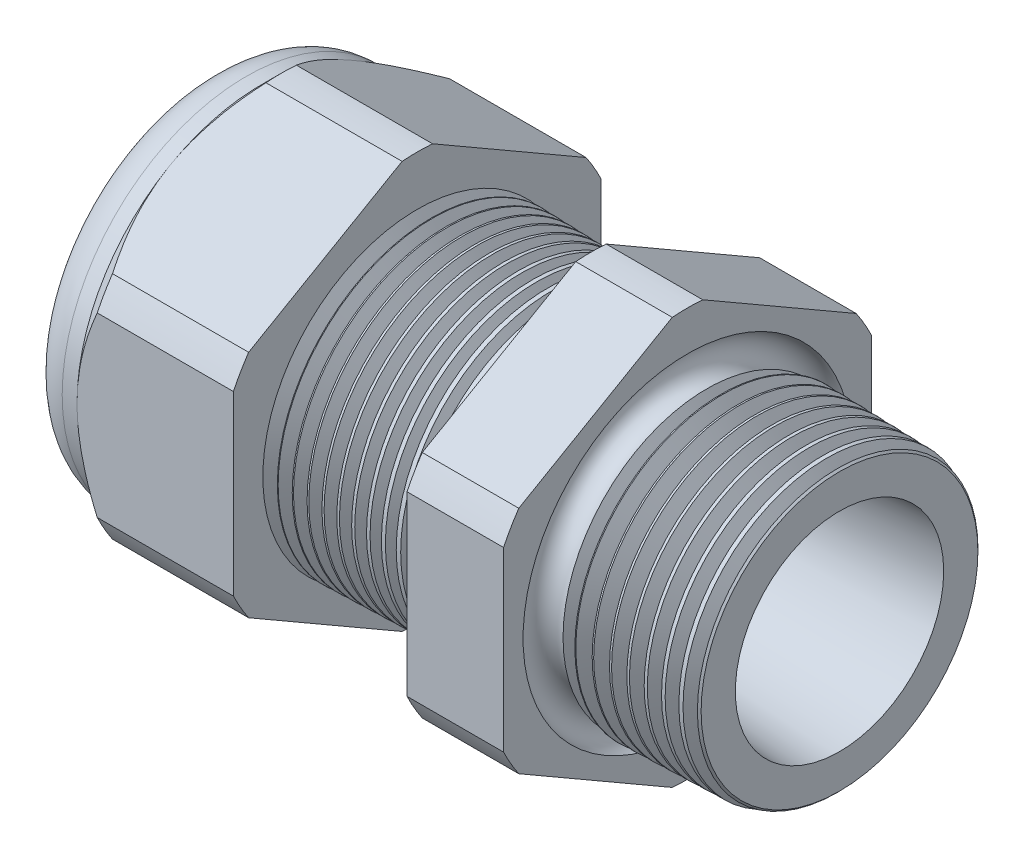
from build123d import *

# Parameters (mm, degrees)
SKETCH12_OUTSIDE_W = 52.712
SKETCH12_OUTSIDE_H = 52.712
CUT_EXTRUDE2_DEPTH = 30.966
FILLET4_R          = 2.032
SKETCH19_OUTSIDE_W = 33.73
SKETCH19_OUTSIDE_H = 35.826
SKETCH19_OUTSIDE_R = 9.525
CUT_EXTRUDE3_DEPTH = 1.999996
CUT_EXTRUDE3_DRAFT = -45
CHAMFER1_SIZE      = 0.260919487
CHAMFER1_SIZE2     = 0.254
SKETCH21_R         = 3.937
PLUG_DEPTH         = 3.81
SKETCH22_R         = 3.683
CUT_EXTRUDE4_DEPTH = 0.508
SKETCH27_R         = 1.778
PLUGHOLES_DEPTH    = 33.258
CIRPATTERN1_COUNT  = 2
LPATTERN1_COUNT    = 12
LPATTERN1_PITCH    = 0.762
LPATTERN2_COUNT    = 9
LPATTERN2_PITCH    = 0.889
SKETCH32_R         = 0.889


with BuildPart() as part:
    # Sketch10 → Revolve2 (revolve)
    with BuildSketch(Plane.XY, mode=Mode.PRIVATE) as revolve2_sk:
        Polygon((-32.766, 3.937), (-21.866, 3.937), (0, 5.396418639), (0, 7.428418639), (-7.874, 7.634606585), (-7.874, 19.05), (-12.874, 19.05), (-12.874, 7.765536193), (-21.866, 8.001), (-21.866, 19.05), (-29.966, 19.05), (-29.966, 9.525), (-32.766, 9.525), align=None)
    revolve(revolve2_sk.sketch.rotate(Axis((0, 0, 0), (-1, 0, 0)), 90), axis=Axis((0, 0, 0), (-1, 0, 0)))  # turned: the seam where the file's is

    # Sketch12 outside → Cut-Extrude2 (cut, through all)
    with BuildSketch(Plane.ZY.offset(29.966)):
        Rectangle(SKETCH12_OUTSIDE_W, SKETCH12_OUTSIDE_H)
        with BuildLine():
            Line((-0.788451287, 10.543310065), (-8.736548713, 5.954473877))
            ThreePointArc((-8.736548713, 5.954473877), (-9.156270088, 5.286375), (-9.525, 4.588836188))
            Line((-9.525, 4.588836188), (-9.525, -4.588836188))
            ThreePointArc((-9.525, -4.588836188), (-9.156270088, -5.286375), (-8.736548713, -5.954473877))
            Line((-8.736548713, -5.954473877), (-0.788451287, -10.543310065))
            ThreePointArc((-0.788451287, -10.543310065), (0, -10.57275), (0.788451287, -10.543310065))
            Line((0.788451287, -10.543310065), (8.736548713, -5.954473877))
            ThreePointArc((8.736548713, -5.954473877), (9.156270088, -5.286375), (9.525, -4.588836188))
            Line((9.525, -4.588836188), (9.525, 4.588836188))
            ThreePointArc((9.525, 4.588836188), (9.156270088, 5.286375), (8.736548713, 5.954473877))
            Line((8.736548713, 5.954473877), (0.788451287, 10.543310065))
            ThreePointArc((0.788451287, 10.543310065), (0, 10.57275), (-0.788451287, 10.543310065))
        make_face(mode=Mode.SUBTRACT)
    extrude(amount=-CUT_EXTRUDE2_DEPTH, mode=Mode.SUBTRACT)

    # Fillet4
    fillet4_edges = [part.edges().sort_by_distance(p)[0] for p in [
        (-32.766, 0, 9.525),
    ]]
    fillet(fillet4_edges, radius=FILLET4_R)


with BuildPart() as cut_extrude3_tool:
    # Sketch19 outside → Cut-Extrude3 (with draft: the straight prism first)
    with BuildSketch(Plane.ZY.offset(29.966)):
        Rectangle(SKETCH19_OUTSIDE_W, SKETCH19_OUTSIDE_H)
        Circle(SKETCH19_OUTSIDE_R, mode=Mode.SUBTRACT)
    extrude(amount=-CUT_EXTRUDE3_DEPTH)
    # Cut-Extrude3: the draft: its side faces are tilted about the plane it starts from
    cut_extrude3_sides = [cut_extrude3_tool.faces().sort_by_distance(p)[0] for p in [
        (-28.966002, -17.913, 0),
        (-28.966002, 0, 16.865),
        (-28.966002, 17.913, 0),
        (-28.966002, 0, -16.865),
        (-28.966002, 0, -9.525),
    ]]
    draft(cut_extrude3_sides, Plane.ZY.offset(29.966), CUT_EXTRUDE3_DRAFT)


with BuildPart() as part_1:
    add(part.part)

    # Cut-Extrude3: cut by cut_extrude3_tool
    add(cut_extrude3_tool.part, mode=Mode.SUBTRACT)

    # Chamfer1
    chamfer1_edges = [part_1.edges().sort_by_distance(p)[0] for p in [
        (0, 0, 7.428418639),
    ]]
    chamfer1_side = [part_1.faces().sort_by_distance(p)[0] for p in [
        (0, 0, 5.606526047),
    ]]
    chamfer(chamfer1_edges, length=CHAMFER1_SIZE, length2=CHAMFER1_SIZE2, reference=chamfer1_side[0])

    # Sketch29 → Cut-Revolve1 (revolve, cut)
    with BuildSketch(Plane.XY, mode=Mode.PRIVATE) as cut_revolve1_sk:
        Polygon((-21.866, 8.001), (-21.133016419, 7.981806149), (-21.516130572, 7.356620673), align=None)
    cut_revolve1 = revolve(cut_revolve1_sk.sketch.rotate(Axis((0, 0, 0), (-1, 0, 0)), 90), axis=Axis((0, 0, 0), (-1, 0, 0)), mode=Mode.SUBTRACT)  # turned: the seam where the file's is

    # LPattern1: Cut-Revolve1 ×12
    with Locations(*[(i * LPATTERN1_PITCH, 0, 0) for i in range(1, LPATTERN1_COUNT)]):
        add(cut_revolve1, mode=Mode.SUBTRACT)

    # Sketch30 → Cut-Revolve2 (revolve, cut)
    with BuildSketch(Plane.XY, mode=Mode.PRIVATE) as cut_revolve2_sk:
        Polygon((-7.874, 7.634606585), (-6.994419703, 7.611573965), (-7.454156686, 6.861351393), align=None)
    cut_revolve2 = revolve(cut_revolve2_sk.sketch.rotate(Axis((0, 0, 0), (-1, 0, 0)), 270), axis=Axis((0, 0, 0), (-1, 0, 0)), mode=Mode.SUBTRACT)  # turned: the seam where the file's is

    # LPattern2: Cut-Revolve2 ×9
    with Locations(*[(i * LPATTERN2_PITCH, 0, 0) for i in range(1, LPATTERN2_COUNT)]):
        add(cut_revolve2, mode=Mode.SUBTRACT)

    # Sketch32 → Cut-Revolve3 (revolve, cut)
    with BuildSketch(Plane.XY, mode=Mode.PRIVATE) as cut_revolve3_sk:
        with Locations((-7.747, 7.634606585)):
            Circle(SKETCH32_R)
    revolve(cut_revolve3_sk.sketch.rotate(Axis((0, 0, 0), (-1, 0, 0)), 270), axis=Axis((0, 0, 0), (-1, 0, 0)), mode=Mode.SUBTRACT)  # turned: the seam where the file's is


with BuildPart() as body_2:
    # Sketch21 → plug (new body)
    with BuildSketch(Plane.ZY.offset(32.766)):
        Circle(SKETCH21_R)
    extrude(amount=-PLUG_DEPTH)

    # Sketch22 → Cut-Extrude4 (cut)
    with BuildSketch(Plane.ZY.offset(32.766)):
        Circle(SKETCH22_R)
    extrude(amount=-CUT_EXTRUDE4_DEPTH, mode=Mode.SUBTRACT)

    # Sketch27 → plugholes (cut, through all)
    with BuildSketch(Plane.ZY.offset(32.258)):
        with Locations((-1.897888, 0)):
            Circle(SKETCH27_R)
    plugholes = extrude(amount=-PLUGHOLES_DEPTH, mode=Mode.SUBTRACT)

    # CirPattern1: plugholes ×2 about axis
    cirpattern1_axis = Axis((0, 0, 0), (1, 0, 0))
    for i in range(1, CIRPATTERN1_COUNT):
        add(plugholes.rotate(cirpattern1_axis, i * 360 / CIRPATTERN1_COUNT), mode=Mode.SUBTRACT)


solid = Compound([part_1.part, body_2.part])
